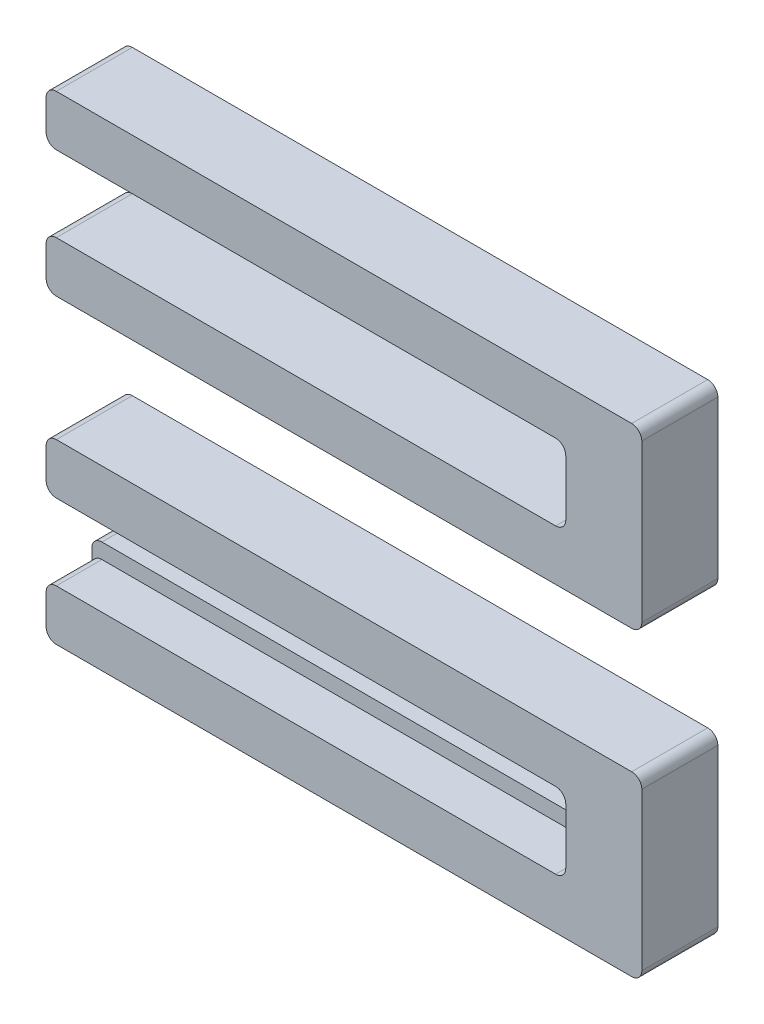
from build123d import *

# Parameters (mm, degrees)
BOSS_EXTRUDE1_DEPTH   = 3
BOSS_EXTRUDE1_2_DEPTH = 3
SKETCH2_4_W           = 20.5
SKETCH2_4_H           = 0.6
BOSS_EXTRUDE3_DEPTH   = 1.2
FILLET2_R             = 0.4
FILLET3_R             = 0.4


with BuildPart() as part:
    # Sketch2 → Boss-Extrude1 (new body)
    with BuildSketch(Plane.XY):
        Polygon((0, 2), (0, 0), (23.5, 0), (23.5, 7), (0, 7), (0, 5), (20.5, 5), (20.5, 2), align=None)
    extrude(amount=BOSS_EXTRUDE1_DEPTH)



with BuildPart() as body_2:
    # Sketch2 → Boss-Extrude1 2 (new body)
    with BuildSketch(Plane.XY):
        Polygon((20.5, -6.899471306), (20.5, -9.899471306), (0, -9.899471306), (0, -11.899471306), (23.5, -11.899471306), (23.5, -4.899471306), (0, -4.899471306), (0, -6.899471306), align=None)
    extrude(amount=BOSS_EXTRUDE1_2_DEPTH)


with BuildPart() as part_1:
    add(part.part)

    add(body_2.part)  # Boss-Extrude3 merges body 2
    # Sketch2_4 → Boss-Extrude3 (add)
    with BuildSketch(Plane.XY):
        with Locations((10.25, 4.7)):
            Rectangle(SKETCH2_4_W, SKETCH2_4_H)
        with Locations((10.25, -9.599471306)):
            Rectangle(SKETCH2_4_W, SKETCH2_4_H)
    extrude(amount=BOSS_EXTRUDE3_DEPTH)

    # Fillet2
    fillet2_edges = [part_1.edges().sort_by_distance(p)[0] for p in [
        (0, 5, 2.1),
        (20.5, 2, 1.5),
        (20.5, 4.4, 0.6),
        (20.5, 5, 2.1),
        (23.5, 7, 1.5),
        (23.5, 0, 1.5),
        (0, 0, 1.5),
        (0, 2, 1.5),
        (0, 4.4, 0.6),
        (0, 7, 1.5),
    ]]
    fillet(fillet2_edges, radius=FILLET2_R)

    # Fillet3
    fillet3_edges = [part_1.edges().sort_by_distance(p)[0] for p in [
        (23.5, -11.899471306, 1.5),
        (23.5, -4.899471306, 1.5),
        (20.5, -6.899471306, 1.5),
        (20.5, -9.899471306, 2.1),
        (20.5, -9.299471306, 0.6),
        (0, -11.899471306, 1.5),
        (0, -9.899471306, 2.1),
        (0, -9.299471306, 0.6),
        (0, -4.899471306, 1.5),
        (0, -6.899471306, 1.5),
    ]]
    fillet(fillet3_edges, radius=FILLET3_R)


solid = part_1.part
